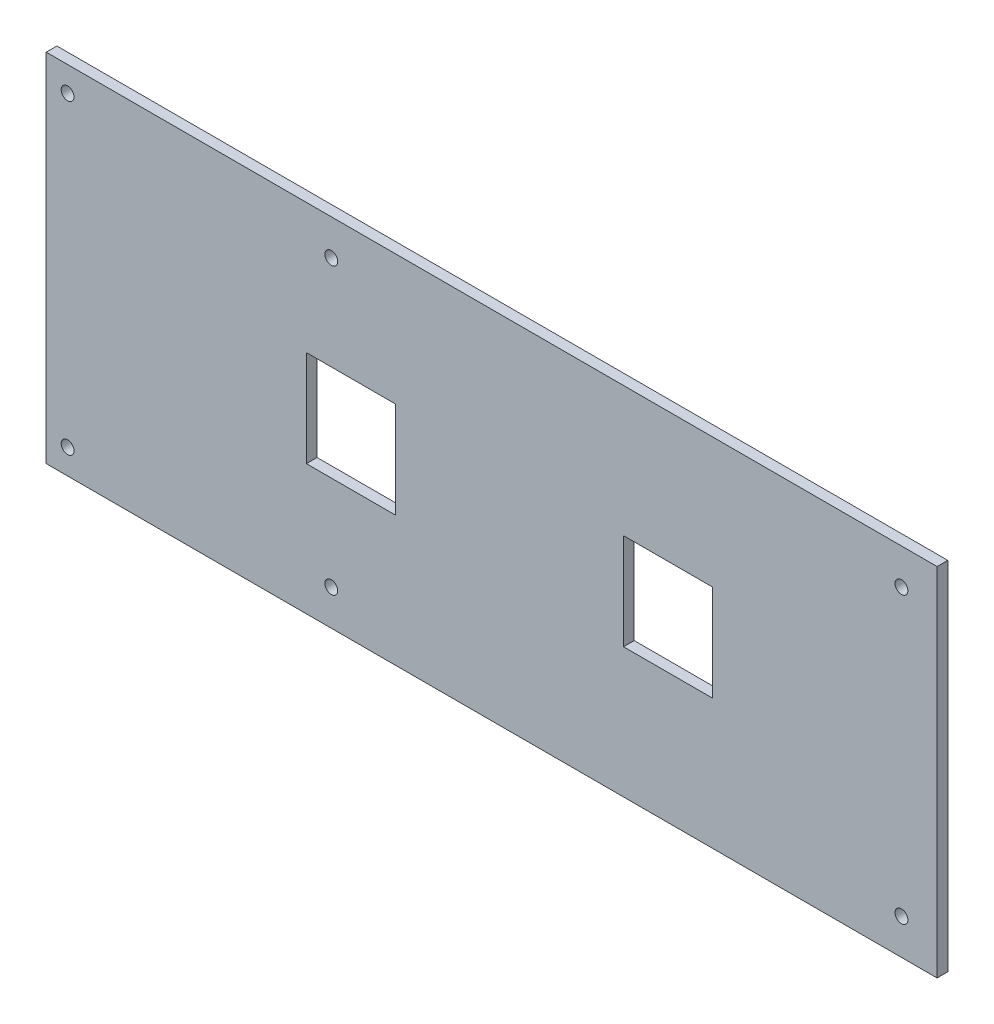
from build123d import *

# Parameters (mm, degrees)
SKETCH1_W           = 250
SKETCH1_H           = 100
BOSS_EXTRUDE1_DEPTH = 3
SKETCH2_R           = 1.8
CUT_EXTRUDE1_DEPTH  = 4
SKETCH3_W           = 25
SKETCH3_H           = 27
CUT_EXTRUDE2_DEPTH  = 4


with BuildPart() as part:
    # Sketch1 → Boss-Extrude1 (new body)
    with BuildSketch(Plane.XY):
        with Locations((125, 50)):
            Rectangle(SKETCH1_W, SKETCH1_H)
    extrude(amount=BOSS_EXTRUDE1_DEPTH)

    # Sketch2 → Cut-Extrude1 (cut, through all)
    with BuildSketch(Plane.XY.offset(3)):
        with Locations((6, 93)):
            Circle(SKETCH2_R)
        with Locations((80, 90)):
            Circle(SKETCH2_R)
        with Locations((240, 90)):
            Circle(SKETCH2_R)
        with Locations((240, 10)):
            Circle(SKETCH2_R)
        with Locations((80, 10)):
            Circle(SKETCH2_R)
        with Locations((6, 7)):
            Circle(SKETCH2_R)
    extrude(amount=-CUT_EXTRUDE1_DEPTH, mode=Mode.SUBTRACT)

    # Sketch3 → Cut-Extrude2 (cut, through all)
    with BuildSketch(Plane.XY.offset(3)):
        with Locations((85.5, 50)):
            Rectangle(SKETCH3_W, SKETCH3_H)
        with Locations((174.5, 50)):
            Rectangle(SKETCH3_W, SKETCH3_H)
    extrude(amount=-CUT_EXTRUDE2_DEPTH, mode=Mode.SUBTRACT)


solid = part.part
